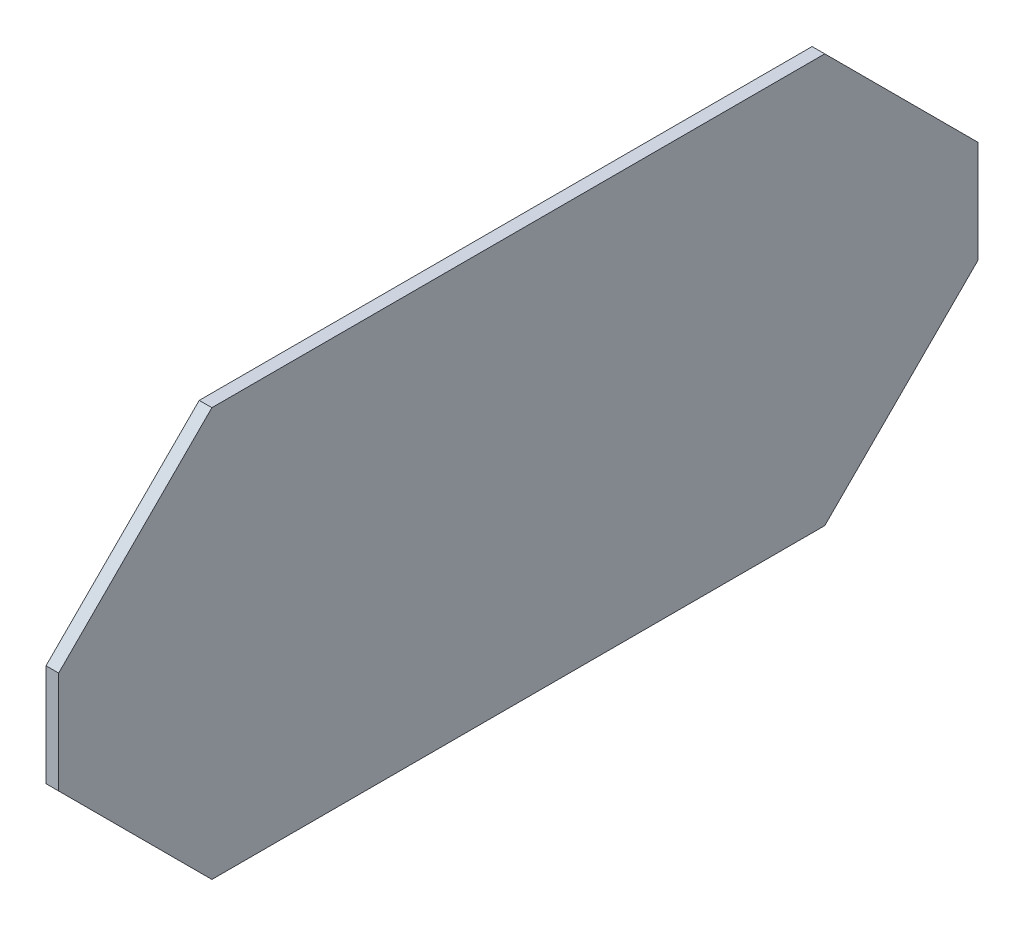
from build123d import *

# Parameters (mm, degrees)
SKETCH1_W              = 0.7874
SKETCH1_H              = 25.4
MCMASTER_2636T21_DEPTH = 28.575
CHAMFER1_SIZE          = 9.525


with BuildPart() as part:
    # Sketch1 → McMaster 2636T21 (new body, symmetric)
    with BuildSketch(Plane.XY):
        Rectangle(SKETCH1_W, SKETCH1_H)
    extrude(amount=MCMASTER_2636T21_DEPTH, both=True)

    # Chamfer1
    chamfer1_edges = [part.edges().sort_by_distance(p)[0] for p in [
        (0, -12.7, 28.575),
        (0, -12.7, -28.575),
        (0, 12.7, -28.575),
        (0, 12.7, 28.575),
    ]]
    chamfer(chamfer1_edges, length=CHAMFER1_SIZE)


solid = part.part
